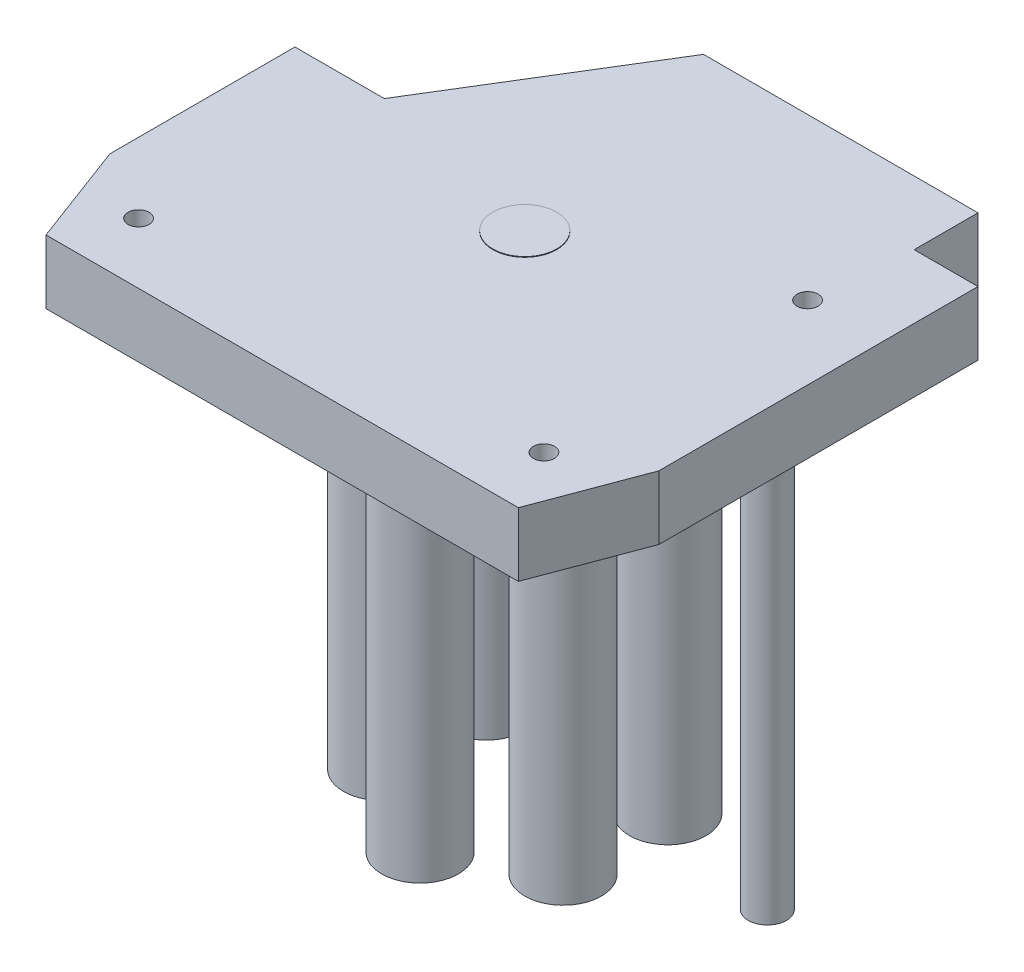
from build123d import *

# Parameters (mm, degrees)
BOSS_EXTRUDE1_DEPTH = 10
CHAMFER1_SIZE       = 6
CHAMFER1_SIZE2      = 16
CHAMFER2_SIZE       = 16
CHAMFER2_SIZE2      = 6
SKETCH2_W           = 10
SKETCH2_H           = 10
CUT_EXTRUDE1_DEPTH  = 10
BOSS_EXTRUDE2_DEPTH = 0.1
SKETCH4_R           = 6
BOSS_EXTRUDE3_DEPTH = 76
SKETCH5_R           = 3
BOSS_EXTRUDE4_DEPTH = 76
SKETCH6_R           = 1.65
CUT_EXTRUDE2_DEPTH  = 11.1
SKETCH7_R           = 1.65
CUT_EXTRUDE3_DEPTH  = 10


with BuildPart() as part:
    # Sketch1 → Boss-Extrude1 (new body)
    with BuildSketch(Plane(origin=(0, 0, 0), x_dir=(1, 0, 0), z_dir=(0, 1, 0))):
        Polygon((0, 0), (0, -45), (86, -45), (86, 31), (33, 31), (14, 0), align=None)
    extrude(amount=BOSS_EXTRUDE1_DEPTH)

    # Chamfer1
    chamfer1_edges = [part.edges().sort_by_distance(p)[0] for p in [
        (86, 5, 45),
    ]]
    chamfer1_side = [part.faces().sort_by_distance(p)[0] for p in [
        (43, 5, 45),
    ]]
    chamfer(chamfer1_edges, length=CHAMFER1_SIZE, length2=CHAMFER1_SIZE2, reference=chamfer1_side[0])

    # Chamfer2
    chamfer2_edges = [part.edges().sort_by_distance(p)[0] for p in [
        (0, 5, 45),
    ]]
    chamfer2_side = [part.faces().sort_by_distance(p)[0] for p in [
        (0, 5, 22.5),
    ]]
    chamfer(chamfer2_edges, length=CHAMFER2_SIZE, length2=CHAMFER2_SIZE2, reference=chamfer2_side[0])

    # Sketch2 → Cut-Extrude1 (cut)
    with BuildSketch(Plane(origin=(0, 10, 0), x_dir=(1, 0, 0), z_dir=(0, 1, 0))):
        with Locations((81, 26)):
            Rectangle(SKETCH2_W, SKETCH2_H)
    extrude(amount=-CUT_EXTRUDE1_DEPTH, mode=Mode.SUBTRACT)

    # Sketch3 → Boss-Extrude2 (add)
    with BuildSketch(Plane(origin=(0, 10, 0), x_dir=(1, 0, 0), z_dir=(0, 1, 0))):
        with BuildLine():
            ThreePointArc((41.3, -2.297872822), (43, -12), (44.7, -2.297872822))
            ThreePointArc((44.7, -2.297872822), (43, -2), (41.3, -2.297872822))
        make_face()
    extrude(amount=BOSS_EXTRUDE2_DEPTH)

    # Sketch4 → Boss-Extrude3 (add)
    with BuildSketch(Plane(origin=(0, 10, 0), x_dir=(1, 0, 0), z_dir=(0, 1, 0))):
        with Locations((43, 9.4)):
            Circle(SKETCH4_R)
        with Locations((57.202816622, 1.2)):
            Circle(SKETCH4_R)
        with Locations((57.202816622, -15.2)):
            Circle(SKETCH4_R)
        with Locations((43, -23.4)):
            Circle(SKETCH4_R)
        with Locations((28.797183378, -15.2)):
            Circle(SKETCH4_R)
        with Locations((28.797183378, 1.2)):
            Circle(SKETCH4_R)
    extrude(amount=-BOSS_EXTRUDE3_DEPTH)

    # Sketch5 → Boss-Extrude4 (add)
    with BuildSketch(Plane(origin=(0, 10, 0), x_dir=(1, 0, 0), z_dir=(0, 1, 0))):
        with Locations((78, -4)):
            Circle(SKETCH5_R)
    extrude(amount=-BOSS_EXTRUDE4_DEPTH)

    # Sketch6 → Cut-Extrude2 (cut, through all)
    with BuildSketch(Plane.XZ):
        with Locations((74.5, -5.8)):
            Circle(SKETCH6_R)
        with Locations((74.5, 35.5)):
            Circle(SKETCH6_R)
        with Locations((11, 35.5)):
            Circle(SKETCH6_R)
    extrude(amount=-CUT_EXTRUDE2_DEPTH, mode=Mode.SUBTRACT)

    # Sketch7 → Cut-Extrude3 (cut)
    with BuildSketch(Plane(origin=(0, 0, -31), x_dir=(-1, 0, 0), z_dir=(0, 0, -1))):
        with Locations((-43, 5)):
            Circle(SKETCH7_R)
    extrude(amount=-CUT_EXTRUDE3_DEPTH, mode=Mode.SUBTRACT)


solid = part.part
